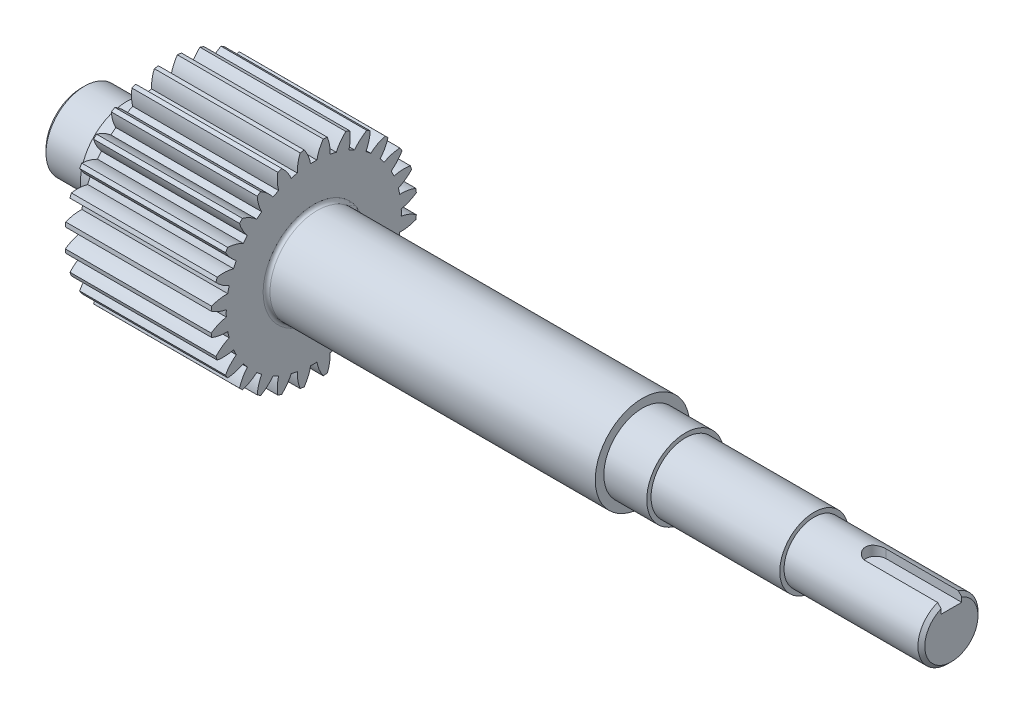
from build123d import *

# Parameters (mm, degrees)
BASPROSKE_W        = 85
BASPROSKE_H        = 60
TOOTHCUT_DEPTH     = 121.104121495
TEETHCUTS_COUNT    = 28
TEETHCUTS_ANGLE    = 347.142857143
BORSKE_R           = 0.4
BORE_DEPTH         = 85.0000508
FILLET1_R          = 2
CHAMFER1_SIZE      = 2
CUT_EXTRUDE1_START = 11.5
CUT_EXTRUDE1_DEPTH = 453.753378485


with BuildPart() as part:
    # BasProSke → Base-Revolve (revolve)
    with BuildSketch(Plane(origin=(0, 0, 0), x_dir=(1, 0, 0), z_dir=(0, 1, 0)), mode=Mode.PRIVATE) as base_revolve_sk:
        with Locations((42.5, 30)):
            Rectangle(BASPROSKE_W, BASPROSKE_H)
    revolve(base_revolve_sk.sketch.rotate(Axis((-10, 0, 0), (1, 0, 0)), 180), axis=Axis((-10, 0, 0), (1, 0, 0)))

    # TooCutSke → ToothCut (cut, through all)
    with BuildSketch(Plane(origin=(0, 0, 0), x_dir=(0, 0, -1), z_dir=(1, 0, 0))):
        with BuildLine():
            ThreePointArc((1.846027594, 50.965578414), (0, 50.999), (-1.846027594, 50.965578414))
            ThreePointArc((-1.846027594, 50.965578414), (-3.219400302, 55.566502749), (-5.541766648, 59.769034354))
            ThreePointArc((-5.541766648, 59.769034354), (0, 60.0254), (5.541766648, 59.769034354))
            ThreePointArc((5.541766648, 59.769034354), (3.219400302, 55.566502749), (1.846027594, 50.965578414))
        make_face()
    toothcut = extrude(amount=TOOTHCUT_DEPTH, mode=Mode.SUBTRACT)

    # TeethCuts: ToothCut ×28 about axis
    teethcuts_axis = Axis((-10, 0, 0), (1, 0, 0))
    for i in range(1, TEETHCUTS_COUNT):
        add(toothcut.rotate(teethcuts_axis, i * TEETHCUTS_ANGLE / (TEETHCUTS_COUNT - 1)), mode=Mode.SUBTRACT)

    # BorSke → Bore (cut, symmetric)
    with BuildSketch(Plane(origin=(0, 0, 0), x_dir=(0, 0, -1), z_dir=(1, 0, 0))):
        with Locations(Location((0, 0, 0), (0, 0, 180))):
            Circle(BORSKE_R)
    extrude(amount=BORE_DEPTH, both=True, mode=Mode.SUBTRACT)

    # Sketch1 → Revolve1 (revolve)
    with BuildSketch(Plane.XY):
        Polygon((0, 0), (456.5, 0), (456.5, 17.5), (376.5, 17.5), (376.5, 20), (301.5, 20), (301.5, 22.5), (276.5, 22.5), (276.5, 27.5), (-23.5, 27.5), (-23.5, 22.5), (-50.5, 22.5), (-50.5, 0), align=None)
    revolve(axis=Axis((309.876576097, 0, 0), (-1, 0, 0)))

    # Fillet1
    fillet1_edges = [part.edges().sort_by_distance(p)[0] for p in [
        (85, -27.5, 0),
        (0, -27.5, 0),
    ]]
    fillet(fillet1_edges, radius=FILLET1_R)

    # Chamfer1
    chamfer1_edges = [part.edges().sort_by_distance(p)[0] for p in [
        (456.5, -17.5, 0),
        (-50.5, -22.5, 0),
    ]]
    chamfer(chamfer1_edges, length=CHAMFER1_SIZE)

    # Sketch2 → Cut-Extrude1 (cut, through all)
    with BuildSketch(Plane(origin=(0, 0, 0), x_dir=(1, 0, 0), z_dir=(0, 1, 0)).offset(CUT_EXTRUDE1_START)):
        with BuildLine():
            Line((412.5, 6), (500.5, 6))
            ThreePointArc((500.5, 6), (506.5, 0), (500.5, -6))
            Line((500.5, -6), (412.5, -6))
            ThreePointArc((412.5, -6), (406.5, 0), (412.5, 6))
        make_face()
    extrude(amount=CUT_EXTRUDE1_DEPTH, mode=Mode.SUBTRACT)


solid = part.part
